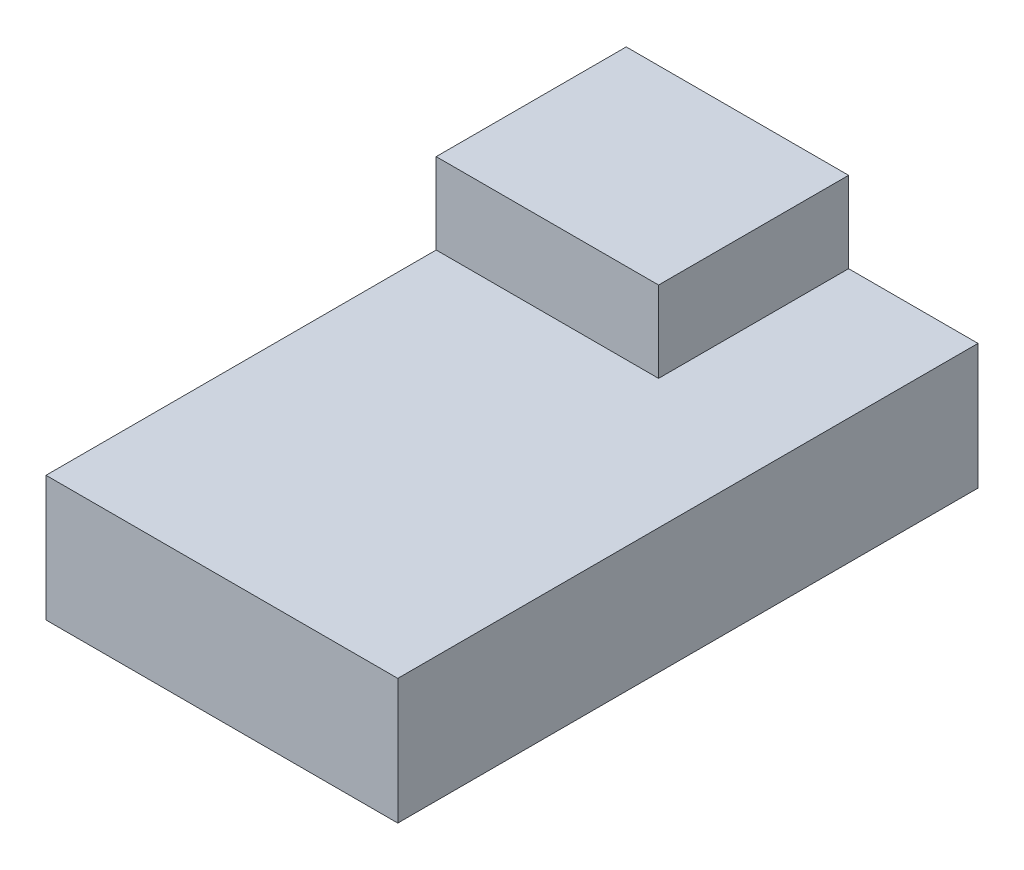
from build123d import *

# Parameters (mm, degrees)
SKETCH1_W      = 22.098
SKETCH1_H      = 36.448752896
EXTRUDE1_DEPTH = 7.874
SKETCH2_W      = 13.97
SKETCH2_H      = 11.938
EXTRUDE2_DEPTH = 5.08


with BuildPart() as part:
    # Sketch1 → Extrude1 (new body)
    with BuildSketch(Plane(origin=(0, 0, 0), x_dir=(1, 0, 0), z_dir=(0, 1, 0))):
        Rectangle(SKETCH1_W, SKETCH1_H)
    extrude(amount=EXTRUDE1_DEPTH)

    # Sketch2 → Extrude2 (add)
    with BuildSketch(Plane(origin=(0, 7.874, 0), x_dir=(-1, 0, 0), z_dir=(0, 1, 0))):
        with Locations((4.064, -12.255376448)):
            Rectangle(SKETCH2_W, SKETCH2_H)
    extrude(amount=EXTRUDE2_DEPTH)


solid = part.part
